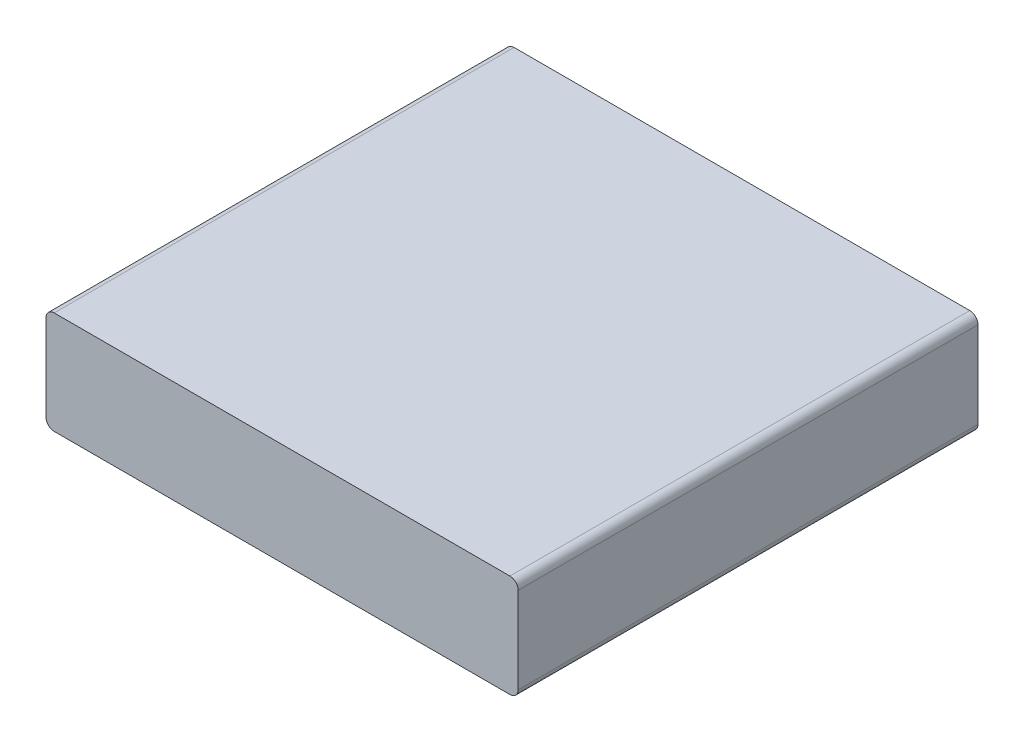
from build123d import *

# Parameters (mm, degrees)
SKETCH1_W           = 115
SKETCH1_H           = 25
BOSS_EXTRUDE1_DEPTH = 112
FILLET1_R           = 2


with BuildPart() as part:
    # Sketch1 → Boss-Extrude1 (new body)
    with BuildSketch(Plane.XY):
        with Locations((28.159722222, 3.385416667)):
            Rectangle(SKETCH1_W, SKETCH1_H)
    extrude(amount=-BOSS_EXTRUDE1_DEPTH)

    # Fillet1
    fillet1_edges = [part.edges().sort_by_distance(p)[0] for p in [
        (-29.340277778, 15.885416667, -56),
        (85.659722222, 15.885416667, -56),
        (85.659722222, -9.114583333, -56),
        (-29.340277778, -9.114583333, -56),
    ]]
    fillet(fillet1_edges, radius=FILLET1_R)


solid = part.part
